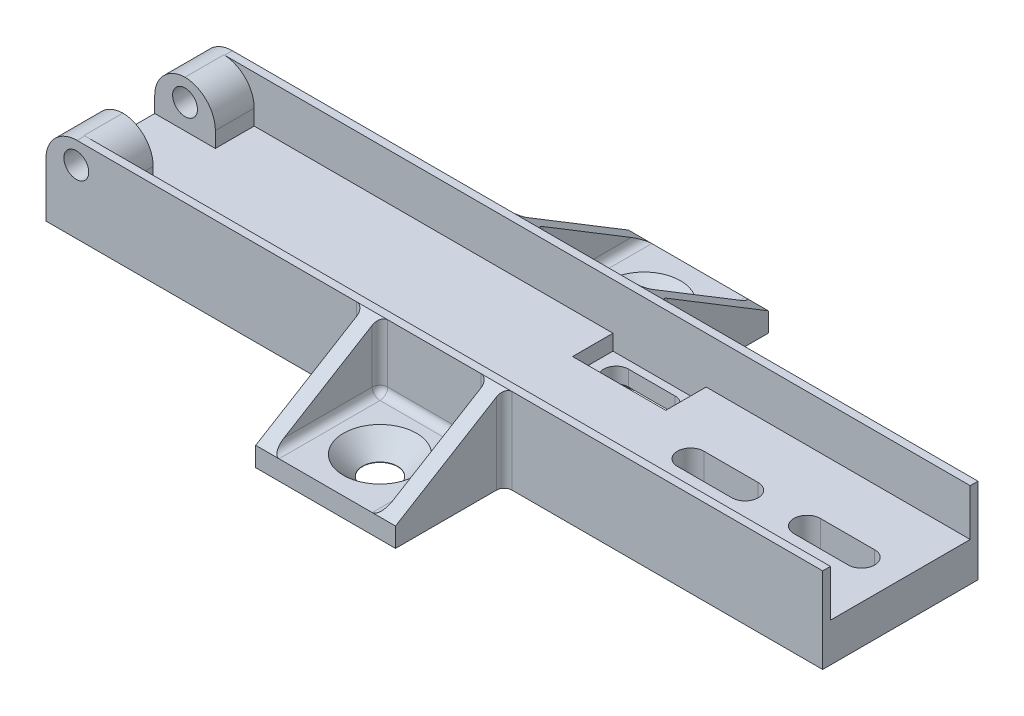
from build123d import *

# Parameters (mm, degrees)
SKETCH1_W            = 100
SKETCH1_H            = 18
BOSS_EXTRUDE1_DEPTH  = 5
SKETCH2_W            = 7.804779938
SKETCH2_H            = 18
BOSS_EXTRUDE2_DEPTH  = 6
FILLET1_R            = 4
CUT_EXTRUDE2_REACH   = 53.981
SKETCH4_W            = 7.804779938
SKETCH4_H            = 8
CUT_EXTRUDE3_DEPTH   = 5
SKETCH8_W            = 100
SKETCH8_H            = 11
BOSS_EXTRUDE5_DEPTH  = 1
SKETCH3_R            = 1.6
CUT_EXTRUDE1_DEPTH   = 55.963624335
FILLET2_R            = 4
SKETCH9_W            = 18
SKETCH9_H            = 2.5
BOSS_EXTRUDE6_DEPTH  = 14
BOSS_EXTRUDE7_DEPTH  = 2
MIRROR5_COPY_1_DEPTH = 2
FILLET4_R            = 1
CUT_EXTRUDE4_REACH   = 57.785
CHAMFER1_SIZE        = 1
SKETCH15_W           = 12
SKETCH15_H           = 5.2
CUT_EXTRUDE5_DEPTH   = 2


with BuildPart() as part:
    # Sketch1 → Boss-Extrude1 (new body)
    with BuildSketch(Plane(origin=(0, 0, 0), x_dir=(1, 0, 0), z_dir=(0, 1, 0))):
        Rectangle(SKETCH1_W, SKETCH1_H)
    extrude(amount=BOSS_EXTRUDE1_DEPTH)

    # Sketch2 → Boss-Extrude2 (add)
    with BuildSketch(Plane(origin=(0, 5, 0), x_dir=(1, 0, 0), z_dir=(0, 1, 0))):
        with Locations((-46.097610031, 0)):
            Rectangle(SKETCH2_W, SKETCH2_H)
    extrude(amount=BOSS_EXTRUDE2_DEPTH)

    # Fillet1
    fillet1_edges = [part.edges().sort_by_distance(p)[0] for p in [
        (-42.195220062, 11, 0),
    ]]
    fillet(fillet1_edges, radius=FILLET1_R)

    # Cut-Extrude2: up to this face of the body (flat: up to its plane)
    cut_extrude2_end = Plane(part.part.faces().sort_by_distance((3.902389969, 5, 0))[0])
    # Sketch4 → Cut-Extrude2 (cut, up to the picked face)
    with BuildSketch(Plane(origin=(0, 11, 0), x_dir=(1, 0, 0), z_dir=(0, 1, 0)), mode=Mode.PRIVATE) as cut_extrude2_sk1:
        with Locations((-46.097610031, 0)):
            Rectangle(SKETCH4_W, SKETCH4_H)
    cut_extrude2_tool1 = split(extrude(cut_extrude2_sk1.sketch, amount=-CUT_EXTRUDE2_REACH, mode=Mode.PRIVATE), bisect_by=cut_extrude2_end, keep=Keep.BOTH, mode=Mode.PRIVATE)
    add(cut_extrude2_tool1.solids().sort_by(Axis((-46.09761, 11, 0), (0, -1, 0)))[0], mode=Mode.SUBTRACT)

    # Sketch5 → Cut-Extrude3 (cut)
    with BuildSketch(Plane.XZ):
        with BuildLine():
            Line((45, -1.7), (38, -1.7))
            ThreePointArc((38, -1.7), (36.3, 0), (38, 1.7))
            Line((38, 1.7), (45, 1.7))
            ThreePointArc((45, 1.7), (46.7, 0), (45, -1.7))
        make_face()
        with BuildLine():
            Line((30, -1.7), (23, -1.7))
            ThreePointArc((23, -1.7), (21.3, 0), (23, 1.7))
            Line((23, 1.7), (30, 1.7))
            ThreePointArc((30, 1.7), (31.7, 0), (30, -1.7))
        make_face()
    extrude(amount=-CUT_EXTRUDE3_DEPTH, mode=Mode.SUBTRACT)

    # Sketch8 → Boss-Extrude5 (add)
    with BuildSketch(Plane.XY.offset(9)):
        with Locations((0, 5.5)):
            Rectangle(SKETCH8_W, SKETCH8_H)
    boss_extrude5 = extrude(amount=BOSS_EXTRUDE5_DEPTH)

    # Mirror1: Boss-Extrude5 across plane
    add(boss_extrude5.mirror(Plane.XY))

    # Sketch3 → Cut-Extrude1 (cut, through all)
    with BuildSketch(Plane.XY.offset(10)):
        with Locations((-46.097610031, 8.2)):
            Circle(SKETCH3_R)
    extrude(amount=-CUT_EXTRUDE1_DEPTH, mode=Mode.SUBTRACT)

    # Fillet2
    fillet2_edges = [part.edges().sort_by_distance(p)[0] for p in [
        (-50, 11, 7),
        (-50, 11, -7),
    ]]
    fillet(fillet2_edges, radius=FILLET2_R)

    # Sketch9 → Boss-Extrude6 (add)
    with BuildSketch(Plane.XY.offset(10)):
        with Locations((0, 1.25)):
            Rectangle(SKETCH9_W, SKETCH9_H)
    boss_extrude6 = extrude(amount=BOSS_EXTRUDE6_DEPTH)

    # Sketch10 → Boss-Extrude7 (add)
    with BuildSketch(Plane(origin=(9, 0, 0), x_dir=(0, 0, -1), z_dir=(1, 0, 0))):
        Polygon((-10, 11), (-24, 2.5), (-10, 2.5), align=None)
    boss_extrude7 = extrude(amount=-BOSS_EXTRUDE7_DEPTH)

    # Mirror2: Boss-Extrude7 across plane
    add(boss_extrude7.mirror(Plane.ZY))

    # Sketch12 → CSK for M4 Countersunk Flat Head Screw1 (revolve, cut)
    with BuildSketch(Plane(origin=(0, 2.5, 17), x_dir=(0, 0, 1), z_dir=(1, 0, 0))):
        Polygon((0, 0), (0, 2.501), (2.25, 2.501), (2.25, 2.45), (4.7, 0), align=None)
    csk_for_m4_countersunk_flat_head_screw1 = revolve(axis=Axis((0, 8.85, 17), (0, -1, 0)), mode=Mode.SUBTRACT)

    # Mirror5: Boss-Extrude6, Boss-Extrude7, CSK for M4 Countersunk Flat Head Screw1 across plane
    add(boss_extrude6.mirror(Plane.XY))
    add(boss_extrude7.mirror(Plane.XY))
    add(csk_for_m4_countersunk_flat_head_screw1.mirror(Plane.XY), mode=Mode.SUBTRACT)

    # Mirror5 copy 1 sketch → Mirror5 copy 1 (add)
    with BuildSketch(Plane.ZY.offset(9)):
        Polygon((-10, 11), (-24, 2.5), (-10, 2.5), align=None)
    extrude(amount=-MIRROR5_COPY_1_DEPTH)

    # Fillet4
    fillet4_edges = [part.edges().sort_by_distance(p)[0] for p in [
        (-9, 5.5, 10),
        (9, 5.5, 10),
        (0, 2.5, 10),
        (7, 6.75, 10),
        (7, 2.5, 17),
        (-7, 6.75, 10),
        (-7, 2.5, 17),
        (-9, 5.5, -10),
        (9, 5.5, -10),
        (0, 2.5, -10),
        (7, 6.75, -10),
        (7, 2.5, -17),
        (-7, 6.75, -10),
        (-7, 2.5, -17),
    ]]
    fillet(fillet4_edges, radius=FILLET4_R)

    # Sketch14 → Cut-Extrude4 (cut, up to next)
    with BuildSketch(Plane(origin=(0, 5, 0), x_dir=(1, 0, 0), z_dir=(0, 1, 0)), mode=Mode.PRIVATE) as cut_extrude4_sk1:
        with BuildLine():
            Line((13, -8), (7, -8))
            ThreePointArc((7, -8), (5.4, -6.4), (7, -4.8))
            Line((7, -4.8), (13, -4.8))
            ThreePointArc((13, -4.8), (14.6, -6.4), (13, -8))
        make_face()
    cut_extrude4_tool1 = extrude(cut_extrude4_sk1.sketch, amount=-CUT_EXTRUDE4_REACH, mode=Mode.PRIVATE) & part.part
    # Sketch14 → Cut-Extrude4 (cut, up to next)
    with BuildSketch(Plane(origin=(0, 5, 0), x_dir=(1, 0, 0), z_dir=(0, 1, 0)), mode=Mode.PRIVATE) as cut_extrude4_sk2:
        with BuildLine():
            Line((13, 8), (7, 8))
            ThreePointArc((7, 8), (5.4, 6.4), (7, 4.8))
            Line((7, 4.8), (13, 4.8))
            ThreePointArc((13, 4.8), (14.6, 6.4), (13, 8))
        make_face()
    cut_extrude4_tool2 = extrude(cut_extrude4_sk2.sketch, amount=-CUT_EXTRUDE4_REACH, mode=Mode.PRIVATE) & part.part
    add(cut_extrude4_tool1.solids().sort_by_distance((10, 5, 6.4))[0], mode=Mode.SUBTRACT)
    add(cut_extrude4_tool2.solids().sort_by_distance((10, 5, -6.4))[0], mode=Mode.SUBTRACT)

    # Chamfer1
    chamfer1_edges = [part.edges().sort_by_distance(p)[0] for p in [
        (10, 0, 4.8),
        (14.6, 0, 6.4),
        (10, 0, 8),
        (5.4, 0, 6.4),
        (10, 0, -8),
        (14.6, 0, -6.4),
        (10, 0, -4.8),
        (5.4, 0, -6.4),
        (46.7, 0, 0),
        (41.5, 0, 1.7),
        (36.3, 0, 0),
        (41.5, 0, -1.7),
        (31.7, 0, 0),
        (26.5, 0, 1.7),
        (21.3, 0, 0),
        (26.5, 0, -1.7),
    ]]
    chamfer(chamfer1_edges, length=CHAMFER1_SIZE)

    # Sketch15 → Cut-Extrude5 (cut)
    with BuildSketch(Plane(origin=(0, 5, 0), x_dir=(1, 0, 0), z_dir=(0, 1, 0))):
        with Locations((10, 6.4)):
            Rectangle(SKETCH15_W, SKETCH15_H)
        with Locations((10, -6.4)):
            Rectangle(SKETCH15_W, SKETCH15_H)
    extrude(amount=-CUT_EXTRUDE5_DEPTH, mode=Mode.SUBTRACT)


solid = part.part
